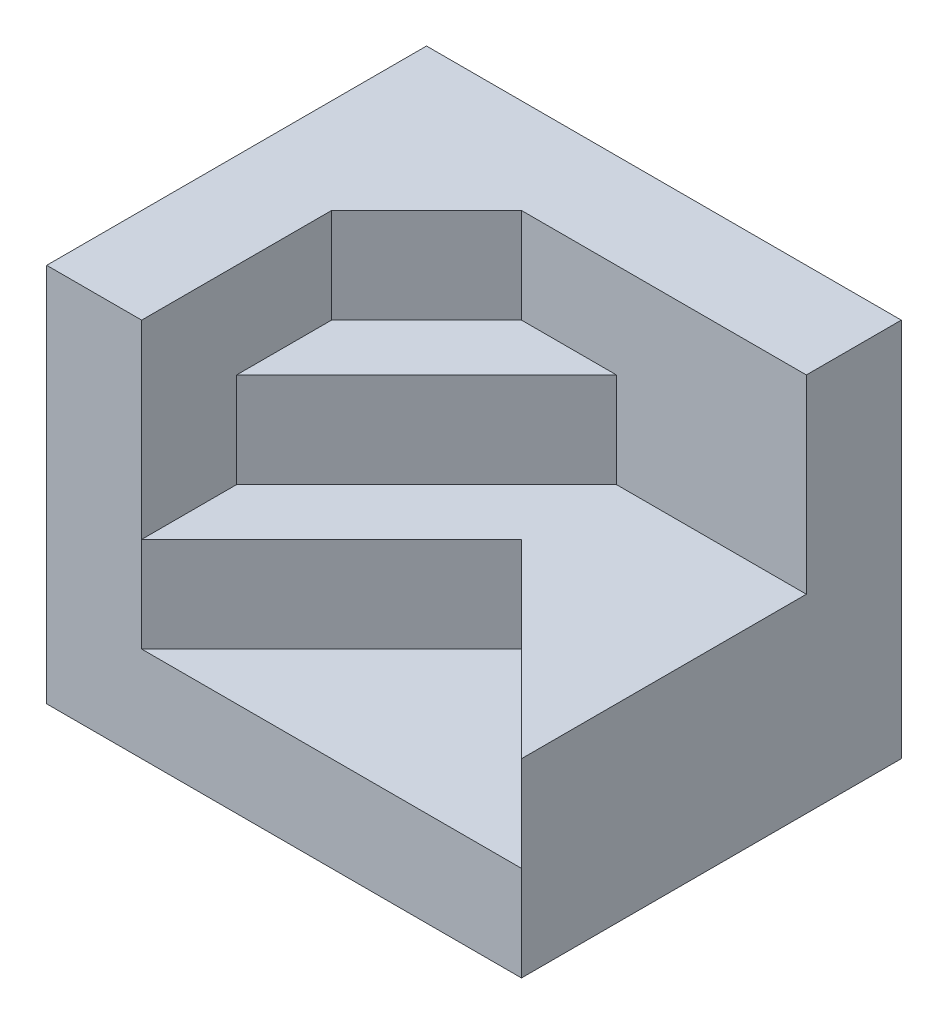
from build123d import *

# Parameters (mm, degrees)
BOSS_EXTRUDE1_DEPTH = 10
BOSS_EXTRUDE2_DEPTH = 20
BOSS_EXTRUDE3_DEPTH = 30
BOSS_EXTRUDE4_DEPTH = 40


with BuildPart() as part:
    # Sketch1 → Boss-Extrude1 (new body)
    with BuildSketch(Plane(origin=(0, 0, 0), x_dir=(1, 0, 0), z_dir=(0, 1, 0))):
        Polygon((30, 20), (10, 0), (50, 0), align=None)
    extrude(amount=BOSS_EXTRUDE1_DEPTH)

    # Sketch1_3 → Boss-Extrude2 (add)
    with BuildSketch(Plane(origin=(0, 0, 0), x_dir=(1, 0, 0), z_dir=(0, 1, 0))):
        Polygon((10, 10), (10, 0), (30, 20), (50, 0), (50, 30), (30, 30), align=None)
    extrude(amount=BOSS_EXTRUDE2_DEPTH)

    # Sketch1_4 → Boss-Extrude3 (add)
    with BuildSketch(Plane(origin=(0, 0, 0), x_dir=(1, 0, 0), z_dir=(0, 1, 0))):
        Polygon((10, 20), (10, 10), (30, 30), (20, 30), align=None)
    extrude(amount=BOSS_EXTRUDE3_DEPTH)

    # Sketch1_5 → Boss-Extrude4 (add)
    with BuildSketch(Plane(origin=(0, 0, 0), x_dir=(1, 0, 0), z_dir=(0, 1, 0))):
        Polygon((0, 40), (0, 0), (10, 0), (10, 10), (10, 20), (20, 30), (30, 30), (50, 30), (50, 40), align=None)
    extrude(amount=BOSS_EXTRUDE4_DEPTH)


solid = part.part
